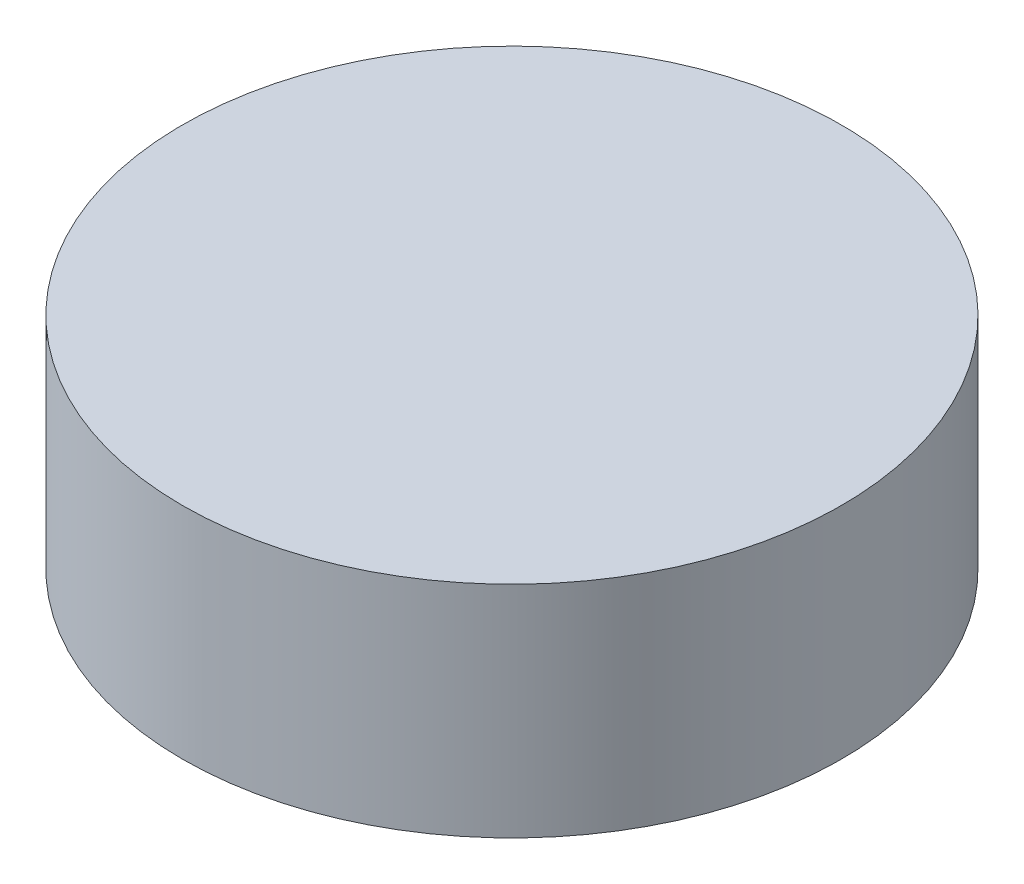
from build123d import *

# Parameters (mm, degrees)
SKETCH2_R           = 15
BOSS_EXTRUDE1_DEPTH = 5
SKETCH4_R           = 3
CUT_EXTRUDE2_DEPTH  = 3


with BuildPart() as part:
    # Sketch2 → Boss-Extrude1 (new body, symmetric)
    with BuildSketch(Plane(origin=(0, 0, 0), x_dir=(1, 0, 0), z_dir=(0, 1, 0))):
        Circle(SKETCH2_R)
    extrude(amount=BOSS_EXTRUDE1_DEPTH, both=True)

    # Sketch4 → Cut-Extrude2 (cut)
    with BuildSketch(Plane(origin=(0, -5, 0), x_dir=(-1, 0, 0), z_dir=(0, -1, 0))):
        Circle(SKETCH4_R)
    extrude(amount=-CUT_EXTRUDE2_DEPTH, mode=Mode.SUBTRACT)


solid = part.part
